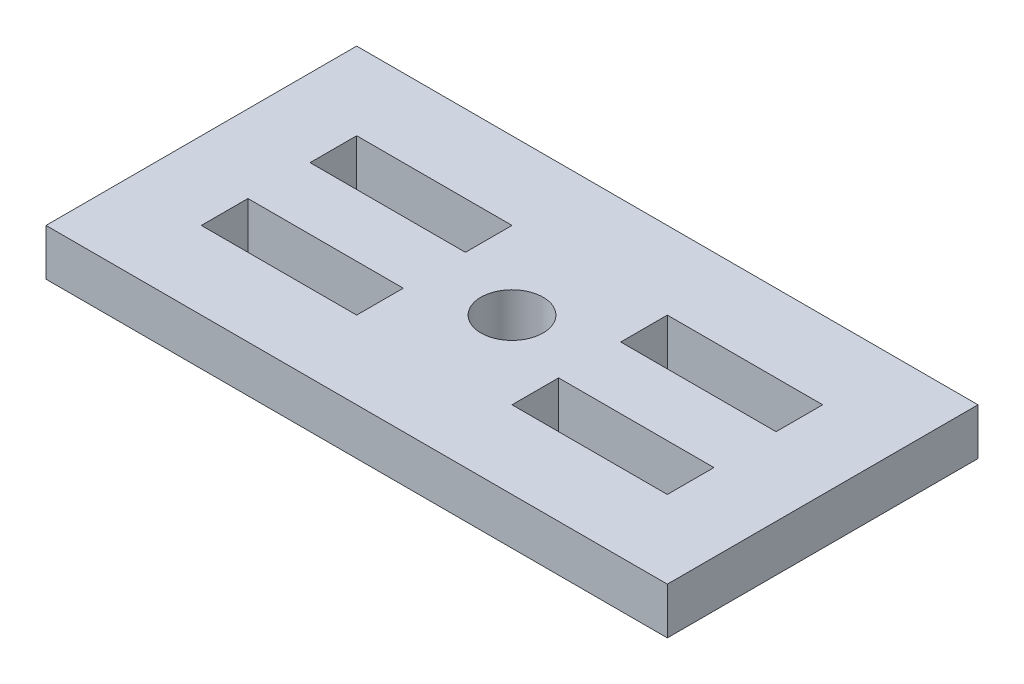
from build123d import *

# Parameters (mm, degrees)
SKETCH1_W           = 20
SKETCH1_H           = 10
BOSS_EXTRUDE1_DEPTH = 1.5
SKETCH3_W           = 5
SKETCH3_H           = 1.5
CUT_EXTRUDE1_DEPTH  = 2
SKETCH2_R           = 1
CUT_EXTRUDE2_DEPTH  = 2


with BuildPart() as part:
    # Sketch1 → Boss-Extrude1 (new body)
    with BuildSketch(Plane(origin=(0, 0, 0), x_dir=(1, 0, 0), z_dir=(0, 1, 0))):
        with Locations((2.275132275, -0.37037037)):
            Rectangle(SKETCH1_W, SKETCH1_H)
    extrude(amount=BOSS_EXTRUDE1_DEPTH)

    # Sketch3 → Cut-Extrude1 (cut)
    with BuildSketch(Plane(origin=(0, 1.5, 0), x_dir=(1, 0, 0), z_dir=(0, 1, 0))):
        with Locations((-2.724867725, 1.37962963)):
            Rectangle(SKETCH3_W, SKETCH3_H)
        with Locations((7.275132275, 1.37962963)):
            Rectangle(SKETCH3_W, SKETCH3_H)
        with Locations((7.275132275, -2.12037037)):
            Rectangle(SKETCH3_W, SKETCH3_H)
        with Locations((-2.724867725, -2.12037037)):
            Rectangle(SKETCH3_W, SKETCH3_H)
    extrude(amount=-CUT_EXTRUDE1_DEPTH, mode=Mode.SUBTRACT)

    # Sketch2 → Cut-Extrude2 (cut)
    with BuildSketch(Plane(origin=(0, 1.5, 0), x_dir=(1, 0, 0), z_dir=(0, 1, 0))):
        with Locations((2.275132275, -0.37037037)):
            Circle(SKETCH2_R)
    extrude(amount=-CUT_EXTRUDE2_DEPTH, mode=Mode.SUBTRACT)


solid = part.part
